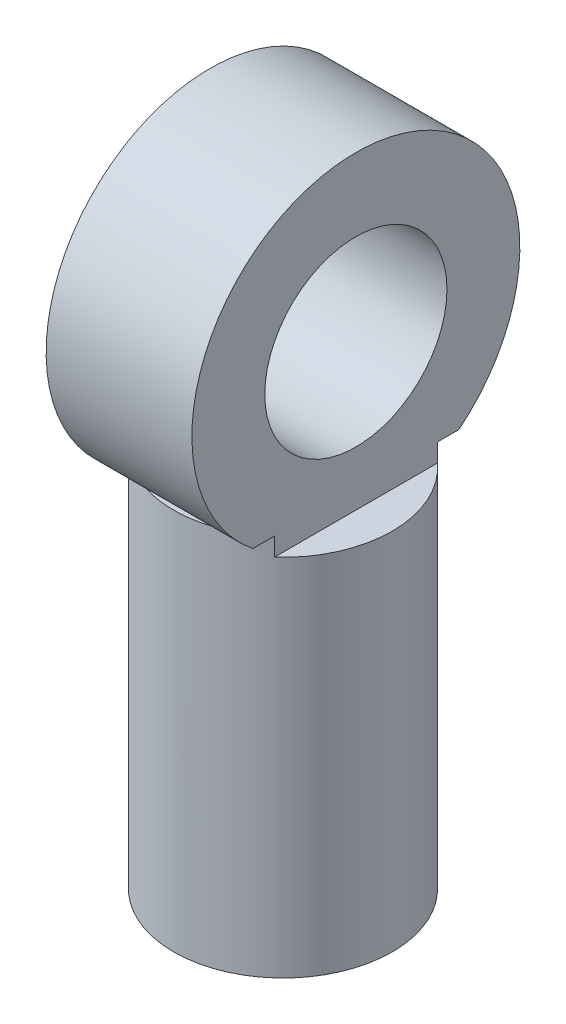
from build123d import *

# Parameters (mm, degrees)
SKETCH1_R                 = 3
CRANK_BODY_DEPTH          = 10
SKETCH2_R                 = 1.65
DOWEL_SHAFT_DEPTH         = 9
PIN_SHAFT_BODY_DEPTH      = 2
PIN_SHAFT_BODY_DEPTH_BACK = 2
SKETCH4_R                 = 2.5
PIN_SHAFT_DEPTH           = 20.685019685
SKETCH1_2_OUTSIDE_W       = 12.286
SKETCH1_2_OUTSIDE_H       = 15.286
SKETCH1_2_OUTSIDE_R       = 3
SMOOTHING_CUTS_DEPTH      = 10.5


with BuildPart() as part:
    # Sketch1 → crank_body (new body)
    with BuildSketch(Plane(origin=(0, 0, 0), x_dir=(1, 0, 0), z_dir=(0, 1, 0))):
        Circle(SKETCH1_R)
    extrude(amount=CRANK_BODY_DEPTH)

    # Sketch2 → dowel_shaft (cut)
    with BuildSketch(Plane.XZ):
        Circle(SKETCH2_R)
    extrude(amount=-DOWEL_SHAFT_DEPTH, mode=Mode.SUBTRACT)

    # Sketch3 → pin_shaft_body (add, two sides: drawn at the far end of the back side and taken through both)
    with BuildSketch(Plane(origin=(0, 0, 0), x_dir=(0, 0, -1), z_dir=(1, 0, 0)).offset(-PIN_SHAFT_BODY_DEPTH_BACK)):
        with BuildLine():
            Line((-3, 10.5), (-3, 10))
            Line((-3, 10), (3, 10))
            Line((3, 10), (3, 10.5))
            Line((3, 10.5), (2.828427125, 10.5))
            ThreePointArc((2.828427125, 10.5), (0, 18.5), (-2.828427125, 10.5))
            Line((-2.828427125, 10.5), (-3, 10.5))
        make_face()
    extrude(amount=PIN_SHAFT_BODY_DEPTH + PIN_SHAFT_BODY_DEPTH_BACK)

    # Sketch4 → pin_shaft (cut, through all)
    with BuildSketch(Plane(origin=(2, 0, 0), x_dir=(0, 0, -1), z_dir=(1, 0, 0))):
        with Locations((0, 14)):
            Circle(SKETCH4_R)
    extrude(amount=-PIN_SHAFT_DEPTH, mode=Mode.SUBTRACT)

    # Sketch1_2 outside → smoothing_cuts (cut)
    with BuildSketch(Plane(origin=(0, 0, 0), x_dir=(1, 0, 0), z_dir=(0, 1, 0))):
        Rectangle(SKETCH1_2_OUTSIDE_W, SKETCH1_2_OUTSIDE_H)
        Circle(SKETCH1_2_OUTSIDE_R, mode=Mode.SUBTRACT)
    extrude(amount=SMOOTHING_CUTS_DEPTH, mode=Mode.SUBTRACT)


solid = part.part
